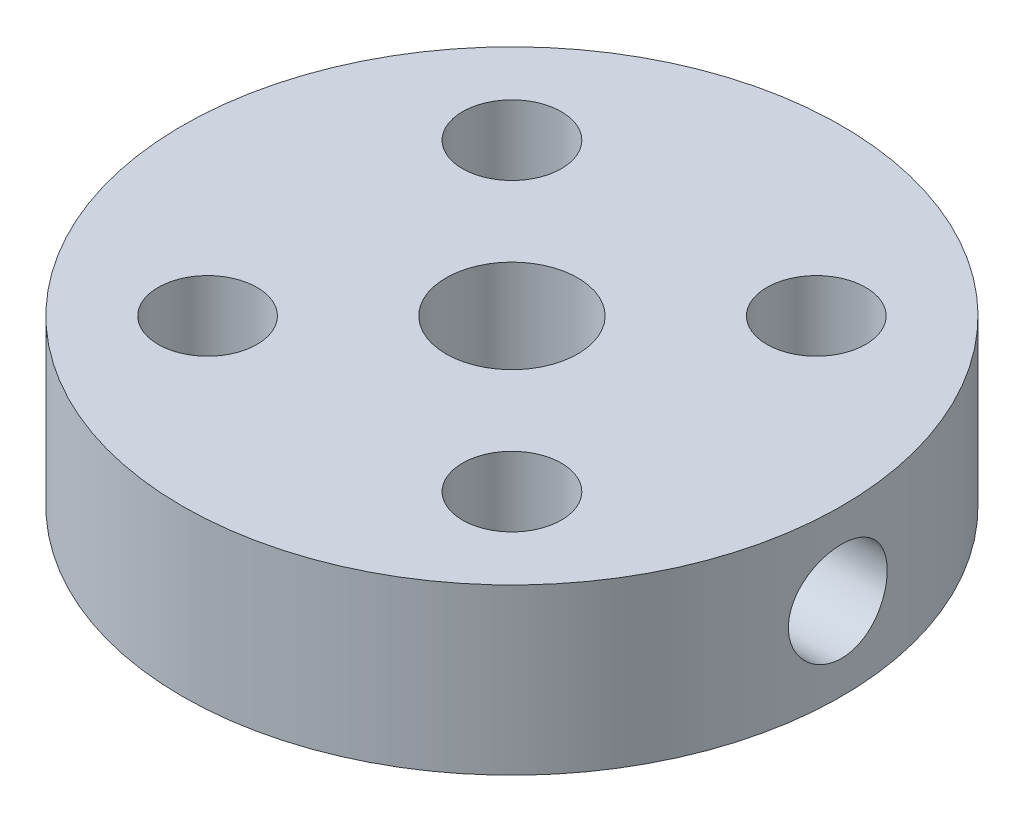
from build123d import *

# Parameters (mm, degrees)
SKETCH_1_R          = 1.5
EXTRUDE_1_DEPTH     = 5
SKETCH_2_R          = 1.5
CUT_EXTRUDE_4_DEPTH = 9


with BuildPart() as part:
    # Эскиз1 → Бобышка-Вытянуть1 (new body)
    with BuildSketch(Plane(origin=(0, 0, 0), x_dir=(1, 0, 0), z_dir=(0, 1, 0))):
        with BuildLine():
            Line((0, 10), (0, 2))
            ThreePointArc((0, 2), (0.765366865, 1.847759065), (1.414213562, 1.414213562))
            Line((1.414213562, 1.414213562), (3.556747109, 3.556747109))
            ThreePointArc((3.556747109, 3.556747109), (3.556747109, 5.678067453), (5.678067453, 5.678067453))
            Line((5.678067453, 5.678067453), (7.071067812, 7.071067812))
            ThreePointArc((7.071067812, 7.071067812), (3.826834324, 9.238795325), (0, 10))
        make_face()
        with BuildLine():
            ThreePointArc((2, 0), (-1.414213562, -1.414213562), (0, 2))
            Line((0, 2), (0, 10))
            ThreePointArc((0, 10), (-7.071067812, -7.071067812), (10, 0))
            ThreePointArc((10, 0), (9.238795325, 3.826834324), (7.071067812, 7.071067812))
            Line((7.071067812, 7.071067812), (5.678067453, 5.678067453))
            ThreePointArc((5.678067453, 5.678067453), (6.00322658, 5.19143243), (6.117407281, 4.617407281))
            ThreePointArc((6.117407281, 4.617407281), (5.19143243, 3.231587982), (3.556747109, 3.556747109))
            Line((3.556747109, 3.556747109), (1.414213562, 1.414213562))
            ThreePointArc((1.414213562, 1.414213562), (1.847759065, 0.765366865), (2, 0))
        make_face()
        with Locations((-4.617407281, -4.617407281)):
            Circle(SKETCH_1_R, mode=Mode.SUBTRACT)
        with Locations((4.617407281, -4.617407281)):
            Circle(SKETCH_1_R, mode=Mode.SUBTRACT)
        with Locations((-4.617407281, 4.617407281)):
            Circle(SKETCH_1_R, mode=Mode.SUBTRACT)
    extrude(amount=EXTRUDE_1_DEPTH)

    # Эскиз2 → Вырез-Вытянуть4 (cut)
    with BuildSketch(Plane(origin=(10, 0, 0), x_dir=(0, 0, -1), z_dir=(1, 0, 0))):
        with Locations((0, 2.5)):
            Circle(SKETCH_2_R)
    extrude(amount=-CUT_EXTRUDE_4_DEPTH, mode=Mode.SUBTRACT)


solid = part.part
